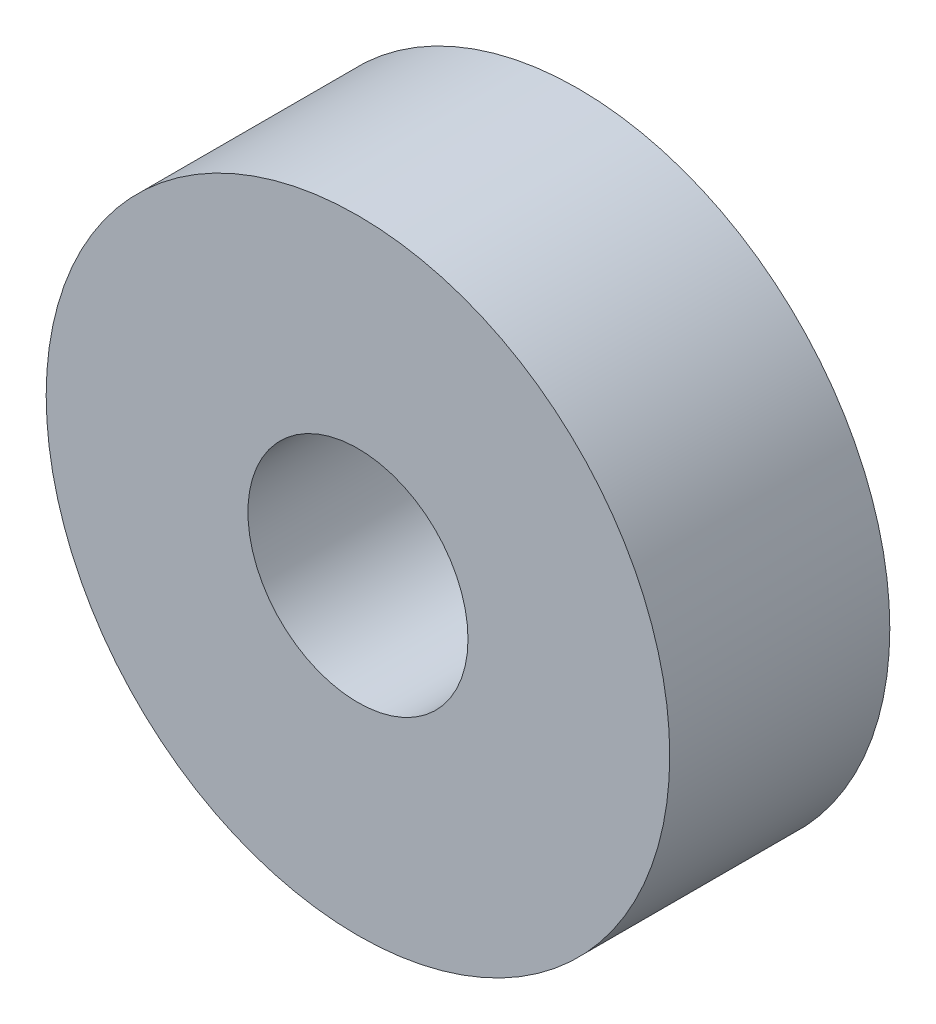
from build123d import *

# Parameters (mm, degrees)
SKETCH1_R           = 8.5
SKETCH1_R_2         = 3
BOSS_EXTRUDE1_DEPTH = 3


with BuildPart() as part:
    # Sketch1 → Boss-Extrude1 (new body, symmetric)
    with BuildSketch(Plane.XY):
        Circle(SKETCH1_R)
        Circle(SKETCH1_R_2, mode=Mode.SUBTRACT)
    extrude(amount=BOSS_EXTRUDE1_DEPTH, both=True)


solid = part.part
